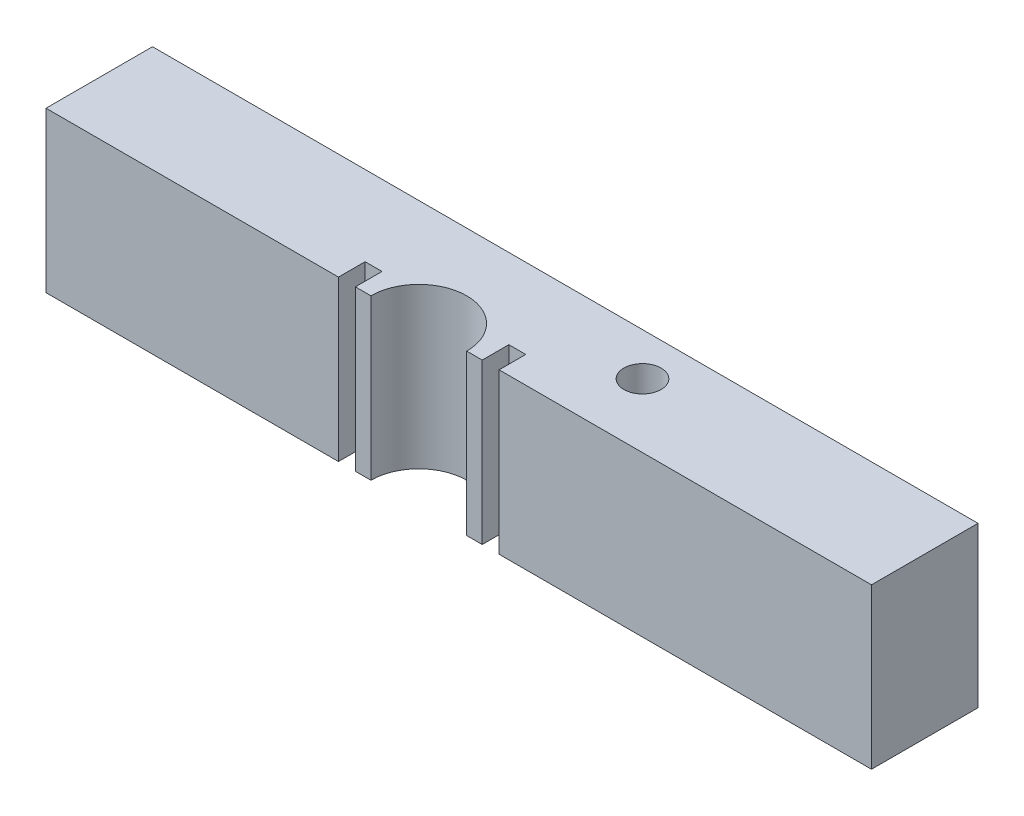
from build123d import *

# Parameters (mm, degrees)
SKETCH1_W           = 155
SKETCH1_H           = 40
SKETCH1_R           = 9
BOSS_EXTRUDE1_DEPTH = 30
SKETCH3_W           = 3.175
SKETCH3_H           = 10
CUT_EXTRUDE2_DEPTH  = 31
SKETCH2_W           = 155
SKETCH2_H           = 30
CUT_EXTRUDE1_DEPTH  = 21
SKETCH4_R           = 3.5
CUT_EXTRUDE3_DEPTH  = 31


with BuildPart() as part:
    # Sketch1 → Boss-Extrude1 (new body)
    with BuildSketch(Plane(origin=(0, 0, 0), x_dir=(1, 0, 0), z_dir=(0, 1, 0))):
        with Locations((7.5, 0)):
            Rectangle(SKETCH1_W, SKETCH1_H)
        Circle(SKETCH1_R, mode=Mode.SUBTRACT)
    extrude(amount=BOSS_EXTRUDE1_DEPTH)

    # Sketch3 → Cut-Extrude2 (cut, through all)
    with BuildSketch(Plane(origin=(0, 30, 0), x_dir=(1, 0, 0), z_dir=(0, 1, 0))):
        with Locations((-13.49375, 0)):
            Rectangle(SKETCH3_W, SKETCH3_H)
        with Locations((13.49375, 0)):
            Rectangle(SKETCH3_W, SKETCH3_H)
    extrude(amount=-CUT_EXTRUDE2_DEPTH, mode=Mode.SUBTRACT)

    # Sketch2 → Cut-Extrude1 (cut, through all)
    with BuildSketch(Plane.XY):
        with Locations((7.5, 15)):
            Rectangle(SKETCH2_W, SKETCH2_H)
    extrude(amount=CUT_EXTRUDE1_DEPTH, mode=Mode.SUBTRACT)

    # Sketch4 → Cut-Extrude3 (cut, through all)
    with BuildSketch(Plane.XZ):
        with Locations((30, -12)):
            Circle(SKETCH4_R)
    extrude(amount=-CUT_EXTRUDE3_DEPTH, mode=Mode.SUBTRACT)


solid = part.part
